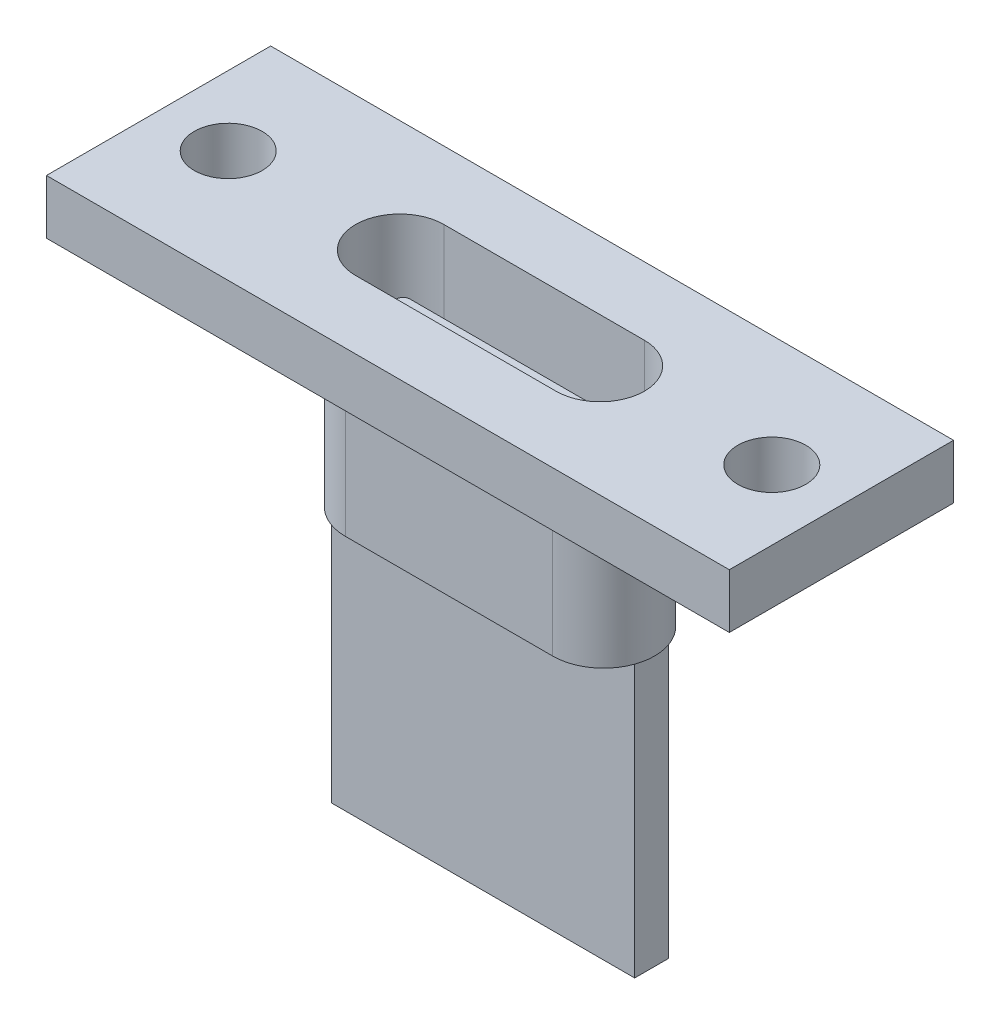
from build123d import *

# Parameters (mm, degrees)
SKETCH_1_W          = 20.1
SKETCH_1_H          = 6.6
EXTRUDE_1_DEPTH     = 1.6
CUT_EXTRUDE_1_REACH = 3.6
SKETCH_2_R          = 1
EXTRUDE_2_DEPTH     = 5
SKETCH_4_W          = 8.928427124
SKETCH_4_H          = 1
EXTRUDE_3_DEPTH     = 8
CUT_EXTRUDE_2_DEPTH = 5
EXTRUDE_4_DEPTH     = 3.5


with BuildPart() as part:
    # 草图1 → 凸台-拉伸1 (new body)
    with BuildSketch(Plane(origin=(0, 0, 0), x_dir=(1, 0, 0), z_dir=(0, 1, 0))):
        Rectangle(SKETCH_1_W, SKETCH_1_H)
    extrude(amount=EXTRUDE_1_DEPTH)

    # 草图2 → 切除-拉伸1 (cut, up to next)
    with BuildSketch(Plane(origin=(0, 1.6, 0), x_dir=(1, 0, 0), z_dir=(0, 1, 0)), mode=Mode.PRIVATE) as cut_extrude_1_sk1:
        with Locations((8, 0)):
            Circle(SKETCH_2_R)
    cut_extrude_1_tool1 = extrude(cut_extrude_1_sk1.sketch, amount=-CUT_EXTRUDE_1_REACH, mode=Mode.PRIVATE) & part.part
    add(cut_extrude_1_tool1.solids().sort_by_distance((8, 1.6, 0))[0], mode=Mode.SUBTRACT)
    # 草图2 → 切除-拉伸1 (cut, up to next)
    with BuildSketch(Plane(origin=(0, 1.6, 0), x_dir=(1, 0, 0), z_dir=(0, 1, 0)), mode=Mode.PRIVATE) as cut_extrude_1_sk2:
        with Locations((-8, 0)):
            Circle(SKETCH_2_R)
    cut_extrude_1_tool2 = extrude(cut_extrude_1_sk2.sketch, amount=-CUT_EXTRUDE_1_REACH, mode=Mode.PRIVATE) & part.part
    add(cut_extrude_1_tool2.solids().sort_by_distance((-8, 1.6, 0))[0], mode=Mode.SUBTRACT)

    # 草图3 → 凸台-拉伸2 (add)
    with BuildSketch(Plane.XZ):
        with BuildLine():
            Line((-3.05, 1.5), (3.05, 1.5))
            ThreePointArc((3.05, 1.5), (4.55, 0), (3.05, -1.5))
            Line((3.05, -1.5), (-3.05, -1.5))
            ThreePointArc((-3.05, -1.5), (-4.55, 0), (-3.05, 1.5))
        make_face()
    extrude(amount=EXTRUDE_2_DEPTH)

    # 草图4 → 凸台-拉伸3 (add)
    with BuildSketch(Plane.XZ.offset(5)):
        Rectangle(SKETCH_4_W, SKETCH_4_H)
    extrude(amount=EXTRUDE_3_DEPTH)

    # 草图5 → 切除-拉伸2 (cut)
    with BuildSketch(Plane(origin=(0, 1.6, 0), x_dir=(1, 0, 0), z_dir=(0, 1, 0))):
        with BuildLine():
            Line((-2.95, 1.3), (2.95, 1.3))
            ThreePointArc((2.95, 1.3), (4.25, 0), (2.95, -1.3))
            Line((2.95, -1.3), (-2.95, -1.3))
            ThreePointArc((-2.95, -1.3), (-4.25, 0), (-2.95, 1.3))
        make_face()
    extrude(amount=-CUT_EXTRUDE_2_DEPTH, mode=Mode.SUBTRACT)

    # 草图6 → 凸台-拉伸4 (add)
    with BuildSketch(Plane(origin=(0, -3.4, 0), x_dir=(1, 0, 0), z_dir=(0, 1, 0))):
        with BuildLine():
            Line((-3.05, -0.4), (3.05, -0.4))
            ThreePointArc((3.05, -0.4), (3.191421356, -0.341421356), (3.25, -0.2))
            Line((3.25, -0.2), (3.25, 0.2))
            ThreePointArc((3.25, 0.2), (3.191421356, 0.341421356), (3.05, 0.4))
            Line((3.05, 0.4), (-3.05, 0.4))
            ThreePointArc((-3.05, 0.4), (-3.191421356, 0.341421356), (-3.25, 0.2))
            Line((-3.25, 0.2), (-3.25, -0.2))
            ThreePointArc((-3.25, -0.2), (-3.191421356, -0.341421356), (-3.05, -0.4))
        make_face()
    extrude(amount=EXTRUDE_4_DEPTH)


solid = part.part
